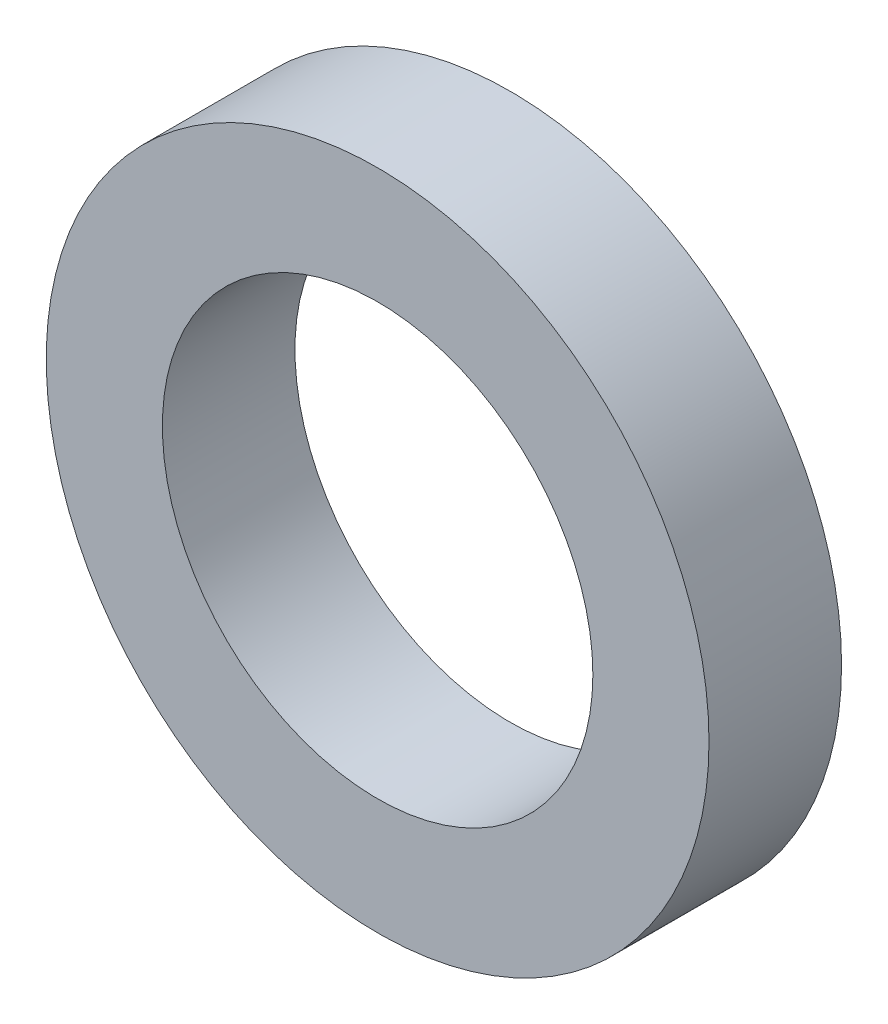
from build123d import *

# Parameters (mm, degrees)
SKETCH1_R           = 5
SKETCH1_R_2         = 3.247595264
BOSS_EXTRUDE1_DEPTH = 2


with BuildPart() as part:
    # Sketch1 → Boss-Extrude1 (new body)
    with BuildSketch(Plane.XY):
        Circle(SKETCH1_R)
        Circle(SKETCH1_R_2, mode=Mode.SUBTRACT)
    extrude(amount=BOSS_EXTRUDE1_DEPTH)


solid = part.part
